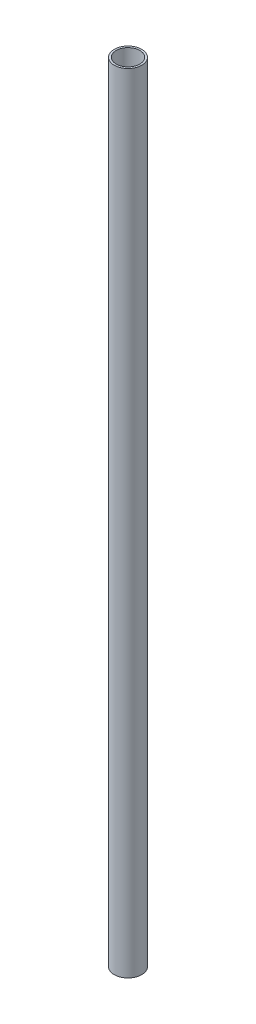
from build123d import *

# Parameters (mm, degrees)
SKETCH_1_R      = 7
SKETCH_1_R_2    = 6
EXTRUDE_1_DEPTH = 400


with BuildPart() as part:
    # Эскиз1 → Бобышка-Вытянуть1 (new body)
    with BuildSketch(Plane(origin=(0, 0, 0), x_dir=(1, 0, 0), z_dir=(0, 1, 0))):
        Circle(SKETCH_1_R)
        Circle(SKETCH_1_R_2, mode=Mode.SUBTRACT)
    extrude(amount=EXTRUDE_1_DEPTH)


solid = part.part
